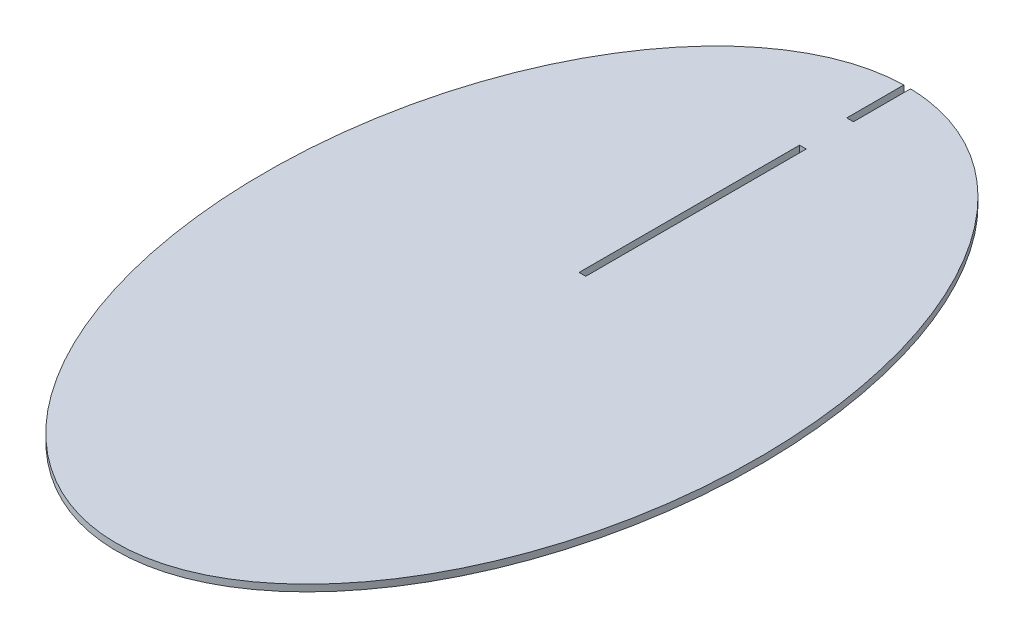
from build123d import *

# Parameters (mm, degrees)
SKETCH1_W           = 1.524
SKETCH1_H           = 50.245395529
BOSS_EXTRUDE1_DEPTH = 1.524


with BuildPart() as part:
    # Sketch1 → Boss-Extrude1 (new body)
    with BuildSketch(Plane(origin=(0, 0, 0), x_dir=(1, 0, 0), z_dir=(0, 1, 0))):
        with BuildLine():
            Line((-0.762, 90.08446874), (-0.762, 77.067849935))
            Line((-0.762, 77.067849935), (0.762, 77.067849935))
            Line((0.762, 77.067849935), (0.762, 90.08446874))
            add(Edge.make_bspline(
                [(-0.762, 90.08446874), (-97.206145449, 87.99315762), (-48.603072725, -45.398110638), (0, -178.789378897), (48.603072725, -45.398110638), (97.206145449, 87.99315762), (0.762, 90.08446874)],
                knots=[0.013542454, 0.013542454, 0.013542454, 2.098909254, 2.098909254, 4.184276054, 4.184276054, 6.269642853, 6.269642853, 6.269642853], degree=2, weights=[1, 0.503904262, 1, 0.503904262, 1, 0.503904262, 1]))
        make_face()
        with Locations((0, 41.197523127)):
            Rectangle(SKETCH1_W, SKETCH1_H, mode=Mode.SUBTRACT)
    extrude(amount=BOSS_EXTRUDE1_DEPTH)


solid = part.part
